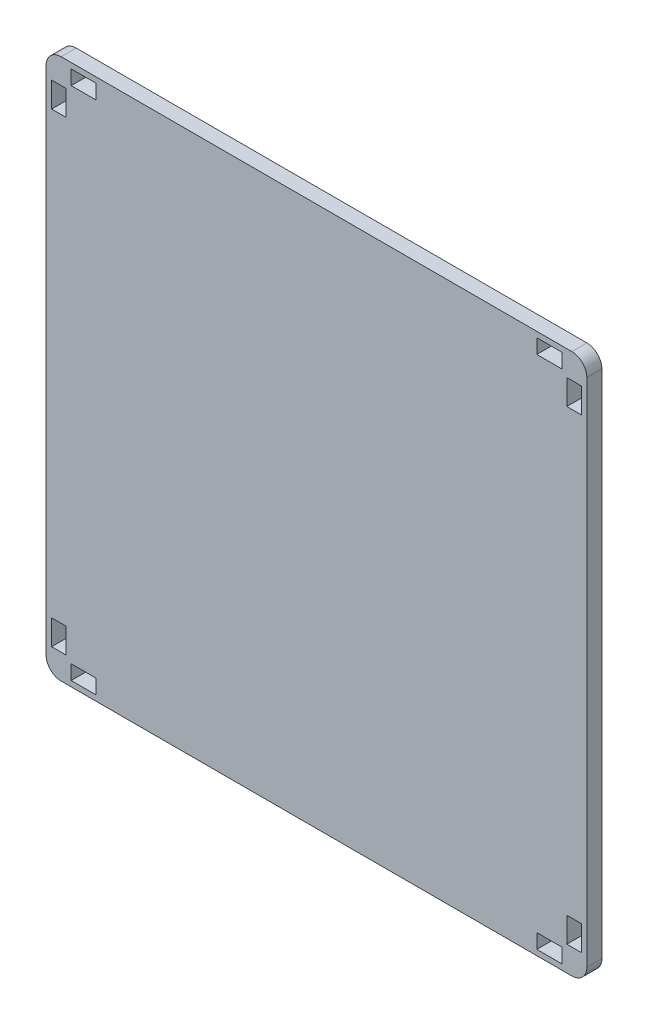
from build123d import *

# Parameters (mm, degrees)
SKETCH_2_W      = 5
SKETCH_2_H      = 2.9
SKETCH_2_W_2    = 2.9
SKETCH_2_H_2    = 5
EXTRUDE_4_DEPTH = 3


with BuildPart() as part:
    # 草图2 → 凸台-拉伸4 (new body)
    with BuildSketch(Plane.XY):
        with BuildLine():
            Line((101, 104), (-1, 104))
            ThreePointArc((-1, 104), (-3.121320344, 103.121320344), (-4, 101))
            Line((-4, 101), (-4, -1))
            ThreePointArc((-4, -1), (-3.121320344, -3.121320344), (-1, -4))
            Line((-1, -4), (101, -4))
            ThreePointArc((101, -4), (103.121320344, -3.121320344), (104, -1))
            Line((104, -1), (104, 101))
            ThreePointArc((104, 101), (103.121320344, 103.121320344), (101, 104))
        make_face()
        with Locations((3.5, -1.45)):
            Rectangle(SKETCH_2_W, SKETCH_2_H, mode=Mode.SUBTRACT)
        with Locations((-1.45, 3.5)):
            Rectangle(SKETCH_2_W_2, SKETCH_2_H_2, mode=Mode.SUBTRACT)
        with Locations((3.5, 101.45)):
            Rectangle(SKETCH_2_W, SKETCH_2_H, mode=Mode.SUBTRACT)
        with Locations((101.45, 3.5)):
            Rectangle(SKETCH_2_W_2, SKETCH_2_H_2, mode=Mode.SUBTRACT)
        with Locations((96.5, -1.45)):
            Rectangle(SKETCH_2_W, SKETCH_2_H, mode=Mode.SUBTRACT)
        with Locations((101.45, 96.5)):
            Rectangle(SKETCH_2_W_2, SKETCH_2_H_2, mode=Mode.SUBTRACT)
        with Locations((96.5, 101.45)):
            Rectangle(SKETCH_2_W, SKETCH_2_H, mode=Mode.SUBTRACT)
        with Locations((-1.45, 96.5)):
            Rectangle(SKETCH_2_W_2, SKETCH_2_H_2, mode=Mode.SUBTRACT)
    extrude(amount=EXTRUDE_4_DEPTH)


solid = part.part
